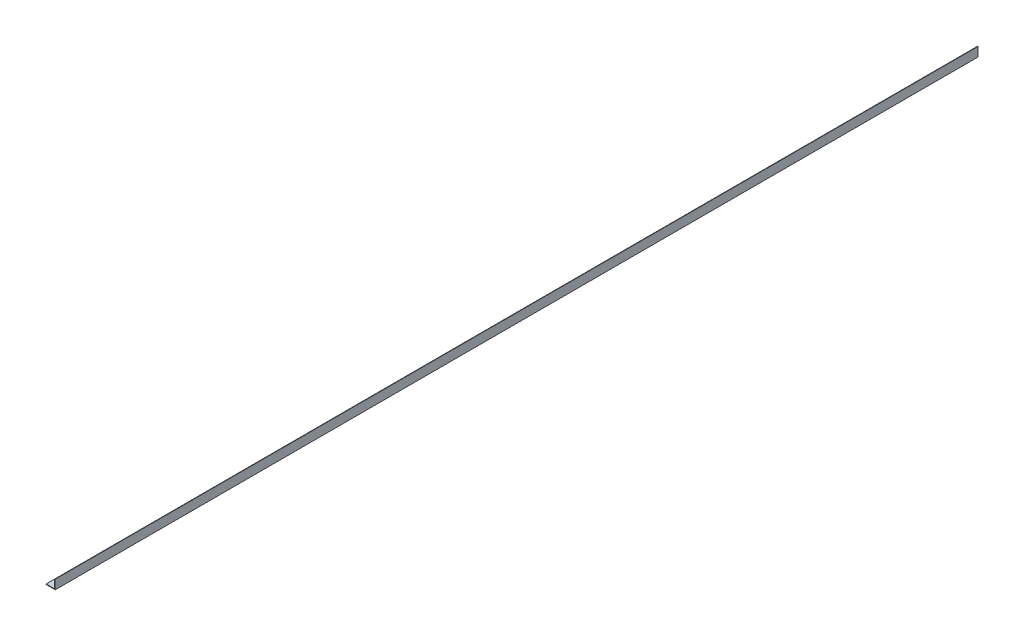
from build123d import *

# Parameters (mm, degrees)
BOSS_EXTRUDE1_DEPTH     = 1270
F_1_4_20_TAPPED_HOLE1_D = 5.1054
CUT_EXTRUDE1_DEPTH      = 2.5875


with BuildPart() as part:
    # Sketch2 → Boss-Extrude1 (new body, symmetric)
    with BuildSketch(Plane.XY):
        with BuildLine():
            Line((-12.7, -12.7), (12.7, -12.7))
            Line((12.7, -12.7), (12.7, 12.7))
            Line((12.7, 12.7), (11.90625, 12.7))
            ThreePointArc((11.90625, 12.7), (11.344983992, 12.467516008), (11.1125, 11.90625))
            Line((11.1125, 11.90625), (11.1125, -9.5377))
            ThreePointArc((11.1125, -9.5377), (10.651251759, -10.651251759), (9.5377, -11.1125))
            Line((9.5377, -11.1125), (-11.90625, -11.1125))
            ThreePointArc((-11.90625, -11.1125), (-12.467516008, -11.344983992), (-12.7, -11.90625))
            Line((-12.7, -11.90625), (-12.7, -12.7))
        make_face()
    extrude(amount=BOSS_EXTRUDE1_DEPTH, both=True)

    # 1/4-20 Tapped Hole1 (through all)
    with Locations(Plane(origin=(0, -11.1125, 0), x_dir=(1, 0, 0), z_dir=(0, 1, 0))):
        with Locations((-1.5875, -349.504), (-1.5875, 106.172), (-1.5875, 1017.524), (-1.5875, 561.848)):
            Hole(F_1_4_20_TAPPED_HOLE1_D / 2)

    # Sketch5 → Cut-Extrude1 (cut, through all)
    with BuildSketch(Plane(origin=(0, -11.1125, 0), x_dir=(1, 0, 0), z_dir=(0, 1, 0))):
        with BuildLine():
            Line((-4.6355, 1057.275), (-4.6355, 1076.325))
            ThreePointArc((-4.6355, 1076.325), (-1.5875, 1079.373), (1.4605, 1076.325))
            Line((1.4605, 1076.325), (1.4605, 1057.275))
            ThreePointArc((1.4605, 1057.275), (-1.5875, 1054.227), (-4.6355, 1057.275))
        make_face()
        with BuildLine():
            Line((1.4605, 660.4), (1.4605, 641.35))
            ThreePointArc((1.4605, 641.35), (-1.5875, 638.302), (-4.6355, 641.35))
            Line((-4.6355, 641.35), (-4.6355, 660.4))
            ThreePointArc((-4.6355, 660.4), (-1.5875, 663.448), (1.4605, 660.4))
        make_face()
        with BuildLine():
            Line((1.4605, -336.55), (1.4605, -317.5))
            ThreePointArc((1.4605, -317.5), (-1.5875, -314.452), (-4.6355, -317.5))
            Line((-4.6355, -317.5), (-4.6355, -336.55))
            ThreePointArc((-4.6355, -336.55), (-1.5875, -339.598), (1.4605, -336.55))
        make_face()
        with BuildLine():
            Line((-4.6355, -717.55), (-4.6355, -1092.2))
            ThreePointArc((-4.6355, -1092.2), (-1.5875, -1095.248), (1.4605, -1092.2))
            Line((1.4605, -1092.2), (1.4605, -717.55))
            ThreePointArc((1.4605, -717.55), (-1.5875, -714.502), (-4.6355, -717.55))
        make_face()
    extrude(amount=-CUT_EXTRUDE1_DEPTH, mode=Mode.SUBTRACT)


solid = part.part
